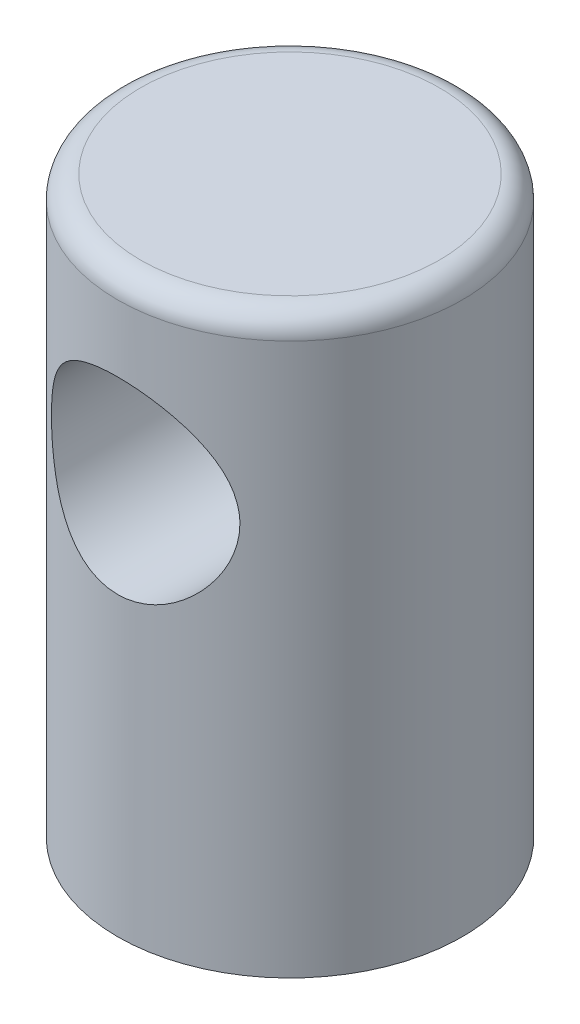
from build123d import *

# Parameters (mm, degrees)
SKETCH1_R               = 7.5
BOSS_EXTRUDE1_DEPTH     = 25
FILLET1_R               = 1
SKETCH2_R               = 4.1
CUT_EXTRUDE1_DEPTH      = 8.5
CUT_EXTRUDE1_DEPTH_BACK = 8.5
M5_TAPPED_HOLE1_D       = 4.2
M5_TAPPED_HOLE1_DEPTH   = 11
M5_TAPPED_HOLE1_TIP     = 1.2618073


with BuildPart() as part:
    # Sketch1 → Boss-Extrude1 (new body)
    with BuildSketch(Plane(origin=(0, 0, 0), x_dir=(1, 0, 0), z_dir=(0, 1, 0))):
        Circle(SKETCH1_R)
    extrude(amount=BOSS_EXTRUDE1_DEPTH)

    # Fillet1
    fillet1_edges = [part.edges().sort_by_distance(p)[0] for p in [
        (-7.5, 25, 0),
    ]]
    fillet(fillet1_edges, radius=FILLET1_R)

    # Sketch2 → Cut-Extrude1 (cut, two sides)
    with BuildSketch(Plane.XY) as cut_extrude1_sk:
        with Locations((0, 17)):
            Circle(SKETCH2_R)
    extrude(amount=CUT_EXTRUDE1_DEPTH, mode=Mode.SUBTRACT)
    extrude(cut_extrude1_sk.sketch, amount=-CUT_EXTRUDE1_DEPTH_BACK, mode=Mode.SUBTRACT)

    # M5 Tapped Hole1
    with Locations(Plane(origin=(0, 0, 0), x_dir=(-1, 0, 0), z_dir=(0, -1, 0))):
        with Locations((0, 0)):
            Hole(M5_TAPPED_HOLE1_D / 2, depth=M5_TAPPED_HOLE1_DEPTH)
            with Locations((0, 0, -(M5_TAPPED_HOLE1_DEPTH + M5_TAPPED_HOLE1_TIP / 2))):  # 118° drill point
                Cone(0, M5_TAPPED_HOLE1_D / 2, M5_TAPPED_HOLE1_TIP, mode=Mode.SUBTRACT)


solid = part.part
